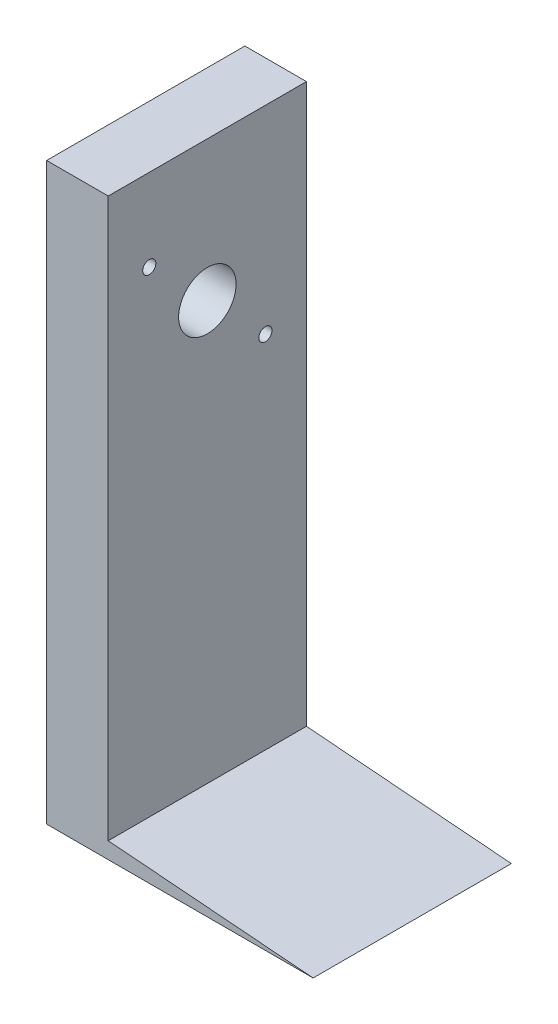
from build123d import *

# Parameters (mm, degrees)
SKETCH1_W           = 61.321024484
SKETCH1_H           = 177.8
SKETCH1_R           = 8.89
SKETCH1_R_2         = 2.032
BOSS_EXTRUDE1_DEPTH = 19.05
BOSS_EXTRUDE2_DEPTH = 61.321024


with BuildPart() as part:
    # Sketch1 → Boss-Extrude1 (new body)
    with BuildSketch(Plane(origin=(0, 0, 0), x_dir=(0, 0, -1), z_dir=(1, 0, 0))):
        Rectangle(SKETCH1_W, SKETCH1_H)
        with Locations((0, 45.539487758)):
            Circle(SKETCH1_R, mode=Mode.SUBTRACT)
        with Locations((-17.960512242, 63.5)):
            Circle(SKETCH1_R_2, mode=Mode.SUBTRACT)
        with Locations((17.960512242, 27.578975516)):
            Circle(SKETCH1_R_2, mode=Mode.SUBTRACT)
    extrude(amount=BOSS_EXTRUDE1_DEPTH)

    # Sketch2 → Boss-Extrude2 (add)
    with BuildSketch(Plane.XY.offset(30.660512242)):
        Polygon((19.05, -88.9), (82.435420259, -88.9), (19.05, -83.82), align=None)
    extrude(amount=-BOSS_EXTRUDE2_DEPTH)


solid = part.part
